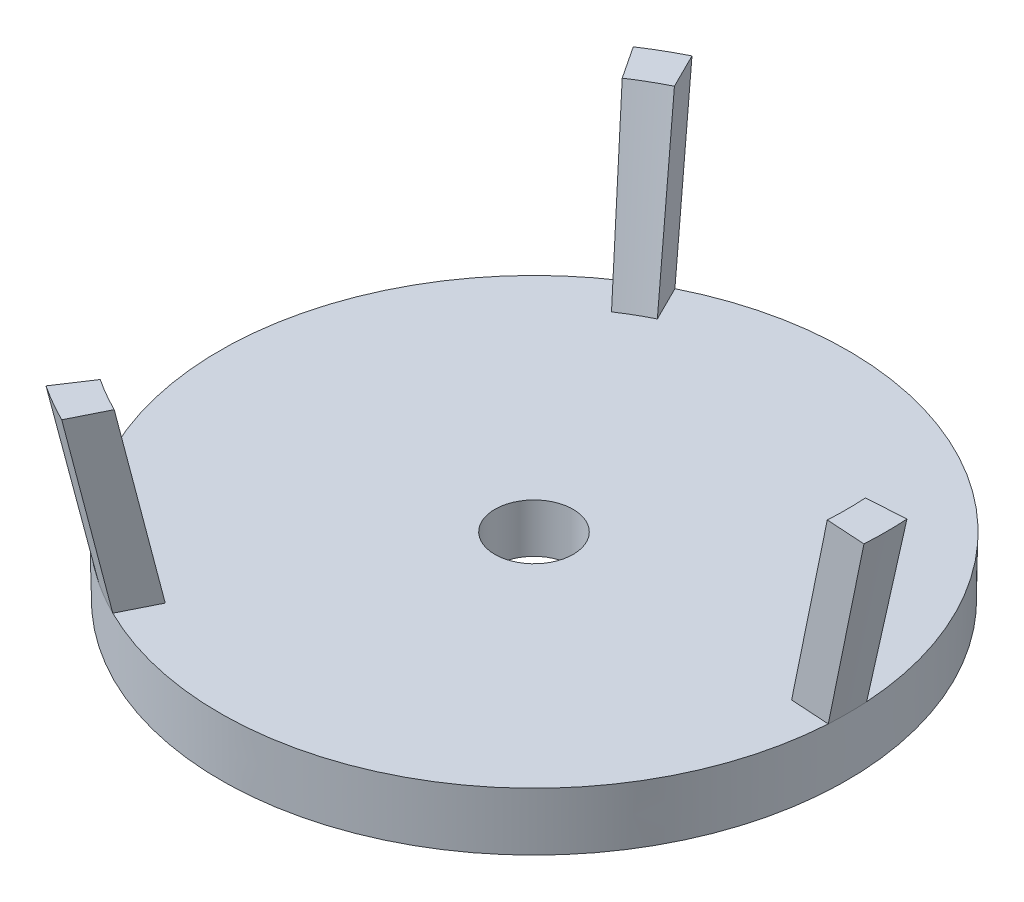
from build123d import *

# Parameters (mm, degrees)
REVOLVE2_ANGLE      = 7
CIRPATTERN1_COUNT   = 3
BOSS_EXTRUDE1_DEPTH = 0.5
BOSS_EXTRUDE1_DRAFT = 45
SKETCH4_R           = 14.13
BOSS_EXTRUDE2_DEPTH = 2
SKETCH5_R           = 2
CUT_EXTRUDE1_DEPTH  = 2.5


with BuildPart() as part:
    # Sketch1 → Revolve1 (revolve)
    with BuildSketch(Plane.XY, mode=Mode.PRIVATE) as revolve1_sk:
        Polygon((14, 0), (14.054310345, 3), (16.054310345, 3), (16, 0), align=None)
    revolve(revolve1_sk.sketch.rotate(Axis((0, 0, 0), (0, 1, 0)), 90), axis=Axis((0, 0, 0), (0, 1, 0)))  # turned: the seam where the file's is

    # Sketch2 → Revolve2 (revolve, symmetric)
    with BuildSketch(Plane.XY) as revolve2_sk:
        Polygon((14.054310345, 3), (16, 12), (18, 12), (16.054310345, 3), align=None)
    revolve2 = revolve(axis=Axis((0, 0, 0), (0, 1, 0)), revolution_arc=REVOLVE2_ANGLE / 2)
    revolve2 = revolve2 + revolve(revolve2_sk.sketch, axis=Axis((0, 0, 0), (0, -1, 0)), revolution_arc=REVOLVE2_ANGLE / 2)

    # CirPattern1: Revolve2 ×3 about axis
    cirpattern1_axis = Axis((0, 0, 0), (0, 1, 0))
    for i in range(1, CIRPATTERN1_COUNT):
        add(revolve2.rotate(cirpattern1_axis, i * 360 / CIRPATTERN1_COUNT))



with BuildPart() as body_2:
    # Sketch3 → Boss-Extrude1 (with draft: the straight prism first)
    with BuildSketch(Plane(origin=(0, 0.5, 0), x_dir=(1, 0, 0), z_dir=(0, 1, 0))):
        with BuildLine():
            ThreePointArc((11.674359761, 0), (8.814058264, 2.414331812), (5.109549882, 2.95))
            ThreePointArc((5.109549882, 2.95), (6.497901814, 6.426032461), (5.837179881, 10.110292126))
            ThreePointArc((5.837179881, 10.110292126), (2.316156449, 8.840364273), (0, 5.9))
            ThreePointArc((0, 5.9), (-2.316156449, 8.840364273), (-5.837179881, 10.110292126))
            ThreePointArc((-5.837179881, 10.110292126), (-6.497901814, 6.426032461), (-5.109549882, 2.95))
            ThreePointArc((-5.109549882, 2.95), (-8.814058264, 2.414331812), (-11.674359761, 0))
            ThreePointArc((-11.674359761, 0), (-8.814058264, -2.414331812), (-5.109549882, -2.95))
            ThreePointArc((-5.109549882, -2.95), (-6.497901814, -6.426032461), (-5.837179881, -10.110292126))
            ThreePointArc((-5.837179881, -10.110292126), (-2.316156449, -8.840364273), (0, -5.9))
            ThreePointArc((0, -5.9), (2.316156449, -8.840364273), (5.837179881, -10.110292126))
            ThreePointArc((5.837179881, -10.110292126), (6.497901814, -6.426032461), (5.109549882, -2.95))
            ThreePointArc((5.109549882, -2.95), (8.814058264, -2.414331812), (11.674359761, 0))
        make_face()
    extrude(amount=BOSS_EXTRUDE1_DEPTH)
    # Boss-Extrude1: the draft: its side faces are tilted about the plane it starts from
    boss_extrude1_sides = [body_2.faces().sort_by_distance(p)[0] for p in [
        (6.497901814, 0.75, 6.426032461),
        (8.814058264, 0.75, 2.414331812),
        (8.814058264, 0.75, -2.414331812),
        (6.497901814, 0.75, -6.426032461),
        (2.316156449, 0.75, -8.840364273),
        (-2.316156449, 0.75, -8.840364273),
        (-6.497901814, 0.75, -6.426032461),
        (-8.814058264, 0.75, -2.414331812),
        (-8.814058264, 0.75, 2.414331812),
        (-6.497901814, 0.75, 6.426032461),
        (-2.316156449, 0.75, 8.840364273),
        (2.316156449, 0.75, 8.840364273),
    ]]
    draft(boss_extrude1_sides, Plane(origin=(0, 0.5, 0), x_dir=(1, 0, 0), z_dir=(0, 1, 0)), BOSS_EXTRUDE1_DRAFT)


with BuildPart() as part_1:
    add(part.part)

    add(body_2.part)  # Boss-Extrude2 merges body 2
    # Sketch4 → Boss-Extrude2 (add)
    with BuildSketch(Plane(origin=(0, 1, 0), x_dir=(1, 0, 0), z_dir=(0, 1, 0))):
        Circle(SKETCH4_R)
    extrude(amount=BOSS_EXTRUDE2_DEPTH)

    # Sketch5 → Cut-Extrude1 (cut)
    with BuildSketch(Plane(origin=(0, 3, 0), x_dir=(1, 0, 0), z_dir=(0, 1, 0))):
        with Locations(Location((0, 0, 0), (0, 0, 270))):  # turned: the seam where the file's is
            Circle(SKETCH5_R)
    extrude(amount=-CUT_EXTRUDE1_DEPTH, mode=Mode.SUBTRACT)


solid = part_1.part
